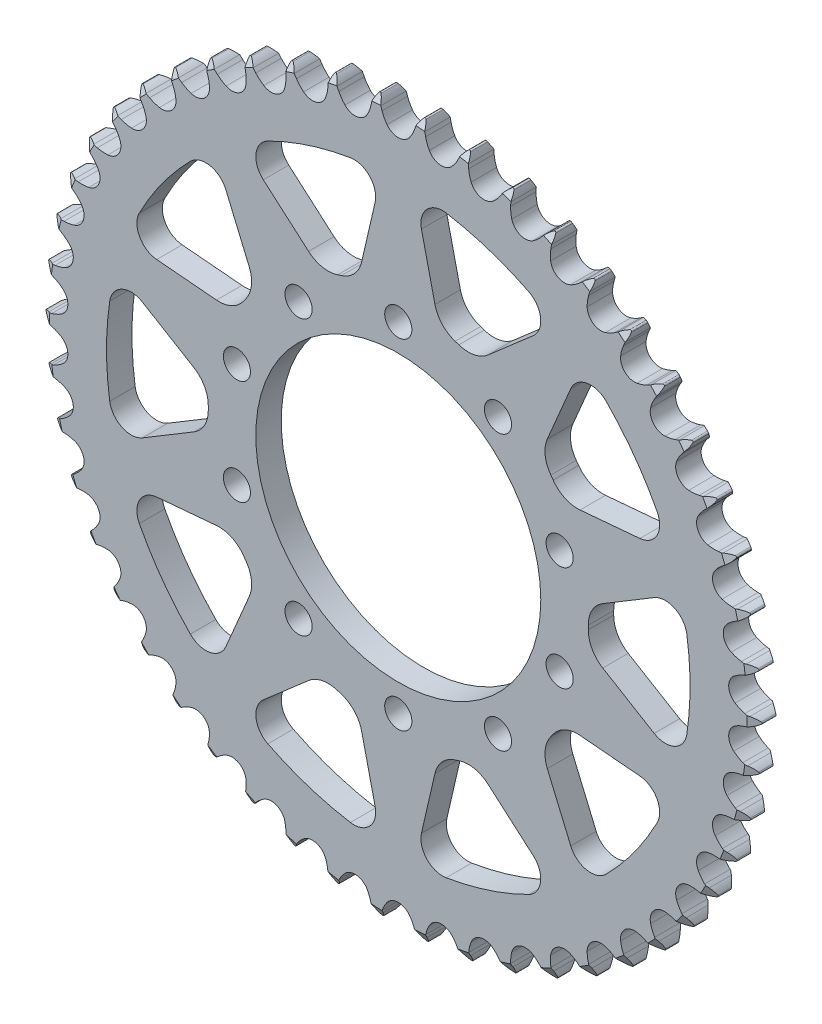
from build123d import *

# Parameters (mm, degrees)
BOSS_EXTRUDE1_DEPTH      = 4.6863
BOSS_EXTRUDE1_DEPTH_BACK = 4.6863
FILLET1_R                = 0.508
CUT_EXTRUDE1_DEPTH       = 187.877669954
CUT_EXTRUDE1_DEPTH_BACK  = 187.877669954
SKETCH2_R                = 5
SKETCH2_R_2              = 52.5
CUT_EXTRUDE2_DEPTH       = 187.877669954
CUT_EXTRUDE2_DEPTH_BACK  = 187.877669954


with BuildPart() as part:
    # Sketch1 → Boss-Extrude1 (new, two sides: drawn at the far end of the back side and taken through both)
    with BuildSketch(Plane.XY.offset(-BOSS_EXTRUDE1_DEPTH_BACK)):
        with BuildLine():
            Line((-5.965842416, 126.821796226), (-6.458669156, 128.227515271))
            ThreePointArc((-6.458669156, 128.227515271), (-7.217923563, 129.819672862), (-8.300150384, 131.21259))
            ThreePointArc((-8.300150384, 131.21259), (-9.199264715, 129.695017442), (-9.752981914, 128.02025468))
            Line((-9.752981914, 128.02025468), (-10.065739255, 126.563852581))
            ThreePointArc((-10.065739255, 126.563852581), (-10.615461473, 124.689641391), (-11.434310422, 122.916410301))
            ThreePointArc((-11.434310422, 122.916410301), (-15.288525396, 120.306617512), (-19.670682192, 121.875914574))
            ThreePointArc((-19.670682192, 121.875914574), (-20.904790136, 123.389796896), (-21.903339188, 125.068415939))
            Line((-21.903339188, 125.068415939), (-22.568463156, 126.4012829))
            ThreePointArc((-22.568463156, 126.4012829), (-23.521280874, 127.885726043), (-24.769552823, 129.132020627))
            ThreePointArc((-24.769552823, 129.132020627), (-25.471375093, 127.513725675), (-25.810822634, 125.78276975))
            Line((-25.810822634, 125.78276975), (-25.938578206, 124.298652928))
            ThreePointArc((-25.938578206, 124.298652928), (-26.249064751, 122.37032199), (-26.839212045, 120.50844437))
            ThreePointArc((-26.839212045, 120.50844437), (-30.335941613, 117.436169351), (-34.88022887, 118.443862156))
            ThreePointArc((-34.88022887, 118.443862156), (-36.29434527, 119.791132325), (-37.495407217, 121.331363574))
            Line((-37.495407217, 121.331363574), (-38.32233901, 122.570358343))
            ThreePointArc((-38.32233901, 122.570358343), (-39.453693535, 123.923676483), (-40.848324617, 125.003693702))
            ThreePointArc((-40.848324617, 125.003693702), (-41.341786669, 123.310197835), (-41.461611262, 121.550346956))
            Line((-41.461611262, 121.550346956), (-41.402350283, 120.06192082))
            ThreePointArc((-41.402350283, 120.06192082), (-41.468704597, 118.109881064), (-41.82084326, 116.188719837))
            ThreePointArc((-41.82084326, 116.188719837), (-44.904941909, 112.702414201), (-49.539693501, 113.132610831))
            ThreePointArc((-49.539693501, 113.132610831), (-51.111516898, 114.292021591), (-52.496150276, 115.669574678))
            Line((-52.496150276, 115.669574678), (-53.471848685, 116.795157568))
            ThreePointArc((-53.471848685, 116.795157568), (-54.76389788, 117.996008069), (-56.28289393, 118.892715407))
            ThreePointArc((-56.28289393, 118.892715407), (-56.560213574, 117.150726066), (-56.458525513, 115.389734134))
            Line((-56.458525513, 115.389734134), (-56.213182563, 113.920472052))
            ThreePointArc((-56.213182563, 113.920472052), (-56.034358199, 111.975508312), (-56.142934795, 110.025361338))
            ThreePointArc((-56.142934795, 110.025361338), (-58.765764446, 106.180006207), (-63.417887573, 106.025922204))
            ThreePointArc((-63.417887573, 106.025922204), (-65.122629372, 106.979188955), (-66.668997685, 108.172339046))
            Line((-66.668997685, 108.172339046), (-67.778075364, 109.166758942))
            ThreePointArc((-67.778075364, 109.166758942), (-69.210442842, 110.196203675), (-70.829848384, 110.89545952))
            ThreePointArc((-70.829848384, 110.89545952), (-70.886652123, 109.132448918), (-70.565055089, 107.398087827))
            Line((-70.565055089, 107.398087827), (-70.137499374, 105.971160941))
            ThreePointArc((-70.137499374, 105.971160941), (-69.716316499, 104.063946457), (-69.57961871, 102.115568717))
            ThreePointArc((-69.57961871, 102.115568717), (-71.699815773, 97.971807639), (-76.295943673, 97.235873))
            ThreePointArc((-76.295943673, 97.235873), (-78.106719078, 97.967962156), (-79.790435175, 98.957892561))
            Line((-79.790435175, 98.957892561), (-81.015401306, 99.805466868))
            ThreePointArc((-81.015401306, 99.805466868), (-82.565497775, 100.647270874), (-84.259773817, 101.138047545))
            ThreePointArc((-84.259773817, 101.138047545), (-84.095165822, 99.381819412), (-83.558731593, 97.701441072))
            Line((-83.558731593, 97.701441072), (-82.955705922, 96.33935287))
            ThreePointArc((-82.955705922, 96.33935287), (-82.298806842, 94.499965554), (-81.918990473, 92.584084131))
            ThreePointArc((-81.918990473, 92.584084131), (-83.503118174, 88.207266693), (-87.970767165, 86.901087547))
            ThreePointArc((-87.970767165, 86.901087547), (-89.859019166, 87.400453624), (-91.653529837, 88.17155255))
            Line((-91.653529837, 88.17155255), (-92.975065973, 88.858914514))
            ThreePointArc((-92.975065973, 88.858914514), (-94.618445487, 89.499802041), (-96.360872283, 89.774359697))
            ThreePointArc((-96.360872283, 89.774359697), (-95.97744852, 88.052610799), (-95.234636985, 86.45271578))
            Line((-95.234636985, 86.45271578), (-94.465651433, 85.176947209))
            ThreePointArc((-94.465651433, 85.176947209), (-93.583395837, 83.434395297), (-92.966450821, 81.581224785))
            ThreePointArc((-92.966450821, 81.581224785), (-93.989526519, 77.040376012), (-98.258239107, 75.184551584))
            ThreePointArc((-98.258239107, 75.184551584), (-100.194188843, 75.443319282), (-102.071193583, 75.983426037))
            Line((-102.071193583, 75.983426037), (-103.468458309, 76.499735549))
            ThreePointArc((-103.468458309, 76.499735549), (-105.17920379, 76.929599418), (-106.94230223, 76.98360812))
            ThreePointArc((-106.94230223, 76.98360812), (-106.346109521, 75.323491467), (-105.408635261, 73.82931107))
            Line((-105.408635261, 73.82931107), (-104.485817189, 72.659981761))
            ThreePointArc((-104.485817189, 72.659981761), (-103.392118777, 71.041746338), (-102.547774703, 69.280512343))
            ThreePointArc((-102.547774703, 69.280512343), (-102.993663884, 64.647244133), (-106.996119922, 62.271041884))
            ThreePointArc((-106.996119922, 62.271041884), (-108.949236308, 62.28513028), (-110.879133631, 62.585727059))
            Line((-110.879133631, 62.585727059), (-112.330091248, 62.92284161))
            ThreePointArc((-112.330091248, 62.92284161), (-114.081223219, 63.134902611), (-115.837188186, 62.96751061))
            ThreePointArc((-115.837188186, 62.96751061), (-115.037628847, 61.395207232), (-113.92027639, 60.030305575))
            Line((-113.92027639, 60.030305575), (-112.858179191, 58.985856549))
            ThreePointArc((-112.858179191, 58.985856549), (-111.570286239, 57.517458154), (-110.511858919, 55.875936388))
            ThreePointArc((-110.511858919, 55.875936388), (-110.373529644, 51.22331815), (-114.046608009, 48.364212207))
            ThreePointArc((-114.046608009, 48.364212207), (-115.986089234, 48.13339912), (-117.938443506, 48.189745332))
            Line((-117.938443506, 48.189745332), (-119.420211546, 48.342348424))
            ThreePointArc((-119.420211546, 48.342348424), (-121.184113609, 48.333262228), (-122.905252487, 47.947109396))
            ThreePointArc((-122.905252487, 47.947109396), (-121.914936046, 46.487415457), (-120.635326709, 45.273317853))
            Line((-120.635326709, 45.273317853), (-119.450700289, 44.370220696))
            ThreePointArc((-119.450700289, 44.370220696), (-117.988923639, 43.07481685), (-116.733105104, 41.578895091))
            ThreePointArc((-116.733105104, 41.578895091), (-116.012738908, 36.980301393), (-119.29851296, 33.683381566))
            ThreePointArc((-119.29851296, 33.683381566), (-121.193772245, 33.211307056), (-123.137793674, 33.022514087))
            Line((-123.137793674, 33.022514087), (-124.627003769, 32.988199078))
            ThreePointArc((-124.627003769, 32.988199078), (-126.375858136, 32.758108981), (-128.035027537, 32.159285177))
            ThreePointArc((-128.035027537, 32.159285177), (-126.869571875, 30.835220924), (-125.447885861, 29.791074418))
            Line((-125.447885861, 29.791074418), (-124.159412488, 29.043571511))
            ThreePointArc((-124.159412488, 29.043571511), (-122.54680523, 27.941591505), (-121.113400488, 26.614861335))
            ThreePointArc((-121.113400488, 26.614861335), (-119.822357977, 22.142814745), (-122.669009096, 18.46007543))
            ThreePointArc((-122.669009096, 18.46007543), (-124.490157071, 17.754184394), (-126.395187277, 17.323229622))
            Line((-126.395187277, 17.323229622), (-127.868353695, 17.10253768))
            ThreePointArc((-127.868353695, 17.10253768), (-129.574579886, 16.655072339), (-131.145613717, 15.853021374))
            ThreePointArc((-131.145613717, 15.853021374), (-129.823398767, 14.685468089), (-128.282056914, 13.827739496))
            Line((-128.282056914, 13.827739496), (-126.910056582, 13.247619407))
            ThreePointArc((-126.910056582, 13.247619407), (-125.172050497, 12.356442125), (-123.583665197, 11.219826869))
            ThreePointArc((-123.583665197, 11.219826869), (-121.742306882, 6.944854236), (-124.10494168, 2.93437443))
            ThreePointArc((-124.10494168, 2.93437443), (-125.823257753, 2.005799191), (-127.659253271, 1.33947903))
            Line((-127.659253271, 1.33947903), (-129.093143297, 0.9358906))
            ThreePointArc((-129.093143297, 0.9358906), (-130.729833108, 0.278106811), (-132.187955227, -0.714522492))
            ThreePointArc((-132.187955227, -0.714522492), (-130.729833108, -1.707151796), (-129.093143297, -2.364935585))
            Line((-129.093143297, -2.364935585), (-127.659253271, -2.768524015))
            ThreePointArc((-127.659253271, -2.768524015), (-125.823257753, -3.434844176), (-124.10494168, -4.363419415))
            ThreePointArc((-124.10494168, -4.363419415), (-121.742306882, -8.373899221), (-123.583665197, -12.648871854))
            ThreePointArc((-123.583665197, -12.648871854), (-125.172050497, -13.78548711), (-126.910056582, -14.676664392))
            Line((-126.910056582, -14.676664392), (-128.282056914, -15.256784481))
            ThreePointArc((-128.282056914, -15.256784481), (-129.823398767, -16.114513074), (-131.145613717, -17.282066359))
            ThreePointArc((-131.145613717, -17.282066359), (-129.574579886, -18.084117324), (-127.868353695, -18.531582665))
            Line((-127.868353695, -18.531582665), (-126.395187277, -18.752274607))
            ThreePointArc((-126.395187277, -18.752274607), (-124.490157071, -19.183229379), (-122.669009096, -19.889120415))
            ThreePointArc((-122.669009096, -19.889120415), (-119.822357977, -23.57185973), (-121.113400488, -28.04390632))
            ThreePointArc((-121.113400488, -28.04390632), (-122.54680523, -29.37063649), (-124.159412488, -30.472616496))
            Line((-124.159412488, -30.472616496), (-125.447885861, -31.220119403))
            ThreePointArc((-125.447885861, -31.220119403), (-126.869571875, -32.264265909), (-128.035027537, -33.588330162))
            ThreePointArc((-128.035027537, -33.588330162), (-126.375858136, -34.187153966), (-124.627003769, -34.417244063))
            Line((-124.627003769, -34.417244063), (-123.137793674, -34.451559072))
            ThreePointArc((-123.137793674, -34.451559072), (-121.193772245, -34.640352041), (-119.29851296, -35.112426551))
            ThreePointArc((-119.29851296, -35.112426551), (-116.012738908, -38.409346378), (-116.733105104, -43.007940076))
            ThreePointArc((-116.733105104, -43.007940076), (-117.988923639, -44.503861835), (-119.450700289, -45.799265681))
            Line((-119.450700289, -45.799265681), (-120.635326709, -46.702362838))
            ThreePointArc((-120.635326709, -46.702362838), (-121.914936046, -47.916460442), (-122.905252487, -49.376154381))
            ThreePointArc((-122.905252487, -49.376154381), (-121.184113609, -49.762307213), (-119.420211546, -49.771393409))
            Line((-119.420211546, -49.771393409), (-117.938443506, -49.618790317))
            ThreePointArc((-117.938443506, -49.618790317), (-115.986089234, -49.562444105), (-114.046608009, -49.793257192))
            ThreePointArc((-114.046608009, -49.793257192), (-110.373529644, -52.652363134), (-110.511858919, -57.304981373))
            ThreePointArc((-110.511858919, -57.304981373), (-111.570286239, -58.946503139), (-112.858179191, -60.414901534))
            Line((-112.858179191, -60.414901534), (-113.92027639, -61.45935056))
            ThreePointArc((-113.92027639, -61.45935056), (-115.037628847, -62.824252217), (-115.837188186, -64.396555595))
            ThreePointArc((-115.837188186, -64.396555595), (-114.081223219, -64.563947596), (-112.330091248, -64.351886595))
            Line((-112.330091248, -64.351886595), (-110.879133631, -64.014772044))
            ThreePointArc((-110.879133631, -64.014772044), (-108.949236308, -63.714175265), (-106.996119922, -63.700086869))
            ThreePointArc((-106.996119922, -63.700086869), (-102.993663884, -66.076289118), (-102.547774703, -70.709557328))
            ThreePointArc((-102.547774703, -70.709557328), (-103.392118777, -72.470791323), (-104.485817189, -74.089026746))
            Line((-104.485817189, -74.089026746), (-105.408635261, -75.258356055))
            ThreePointArc((-105.408635261, -75.258356055), (-106.346109521, -76.752536452), (-106.94230223, -78.412653105))
            ThreePointArc((-106.94230223, -78.412653105), (-105.17920379, -78.358644403), (-103.468458309, -77.928780534))
            Line((-103.468458309, -77.928780534), (-102.071193583, -77.412471022))
            ThreePointArc((-102.071193583, -77.412471022), (-100.194188843, -76.872364267), (-98.258239107, -76.613596569))
            ThreePointArc((-98.258239107, -76.613596569), (-93.989526519, -78.469420997), (-92.966450821, -83.01026977))
            ThreePointArc((-92.966450821, -83.01026977), (-93.583395837, -84.863440282), (-94.465651433, -86.605992194))
            Line((-94.465651433, -86.605992194), (-95.234636985, -87.881760765))
            ThreePointArc((-95.234636985, -87.881760765), (-95.97744852, -89.481655784), (-96.360872283, -91.203404682))
            ThreePointArc((-96.360872283, -91.203404682), (-94.618445487, -90.928847026), (-92.975065973, -90.287959498))
            Line((-92.975065973, -90.287959498), (-91.653529837, -89.600597535))
            ThreePointArc((-91.653529837, -89.600597535), (-89.859019166, -88.829498609), (-87.970767165, -88.330132532))
            ThreePointArc((-87.970767165, -88.330132532), (-83.503118174, -89.636311678), (-81.918990473, -94.013129116))
            ThreePointArc((-81.918990473, -94.013129116), (-82.298806842, -95.929010539), (-82.955705922, -97.768397855))
            Line((-82.955705922, -97.768397855), (-83.558731593, -99.130486057))
            ThreePointArc((-83.558731593, -99.130486057), (-84.095165822, -100.810864397), (-84.259773817, -102.56709253))
            ThreePointArc((-84.259773817, -102.56709253), (-82.565497775, -102.076315859), (-81.015401306, -101.234511853))
            Line((-81.015401306, -101.234511853), (-79.790435175, -100.386937546))
            ThreePointArc((-79.790435175, -100.386937546), (-78.106719078, -99.397007141), (-76.295943673, -98.664917985))
            ThreePointArc((-76.295943673, -98.664917985), (-71.699815773, -99.400852624), (-69.57961871, -103.544613702))
            ThreePointArc((-69.57961871, -103.544613702), (-69.716316499, -105.492991442), (-70.137499374, -107.400205925))
            Line((-70.137499374, -107.400205925), (-70.565055089, -108.827132812))
            ThreePointArc((-70.565055089, -108.827132812), (-70.886652123, -110.561493903), (-70.829848384, -112.324504505))
            ThreePointArc((-70.829848384, -112.324504505), (-69.210442842, -111.62524866), (-67.778075364, -110.595803927))
            Line((-67.778075364, -110.595803927), (-66.668997685, -109.601384031))
            ThreePointArc((-66.668997685, -109.601384031), (-65.122629372, -108.40823394), (-63.417887573, -107.454967189))
            ThreePointArc((-63.417887573, -107.454967189), (-58.765764446, -107.609051192), (-56.142934795, -111.454406323))
            ThreePointArc((-56.142934795, -111.454406323), (-56.034358199, -113.404553297), (-56.213182563, -115.349517037))
            Line((-56.213182563, -115.349517037), (-56.458525513, -116.818779119))
            ThreePointArc((-56.458525513, -116.818779119), (-56.560213574, -118.579771051), (-56.28289393, -120.321760392))
            ThreePointArc((-56.28289393, -120.321760392), (-54.76389788, -119.425053054), (-53.471848685, -118.224202553))
            Line((-53.471848685, -118.224202553), (-52.496150276, -117.098619663))
            ThreePointArc((-52.496150276, -117.098619663), (-51.111516898, -115.721066576), (-49.539693501, -114.561655816))
            ThreePointArc((-49.539693501, -114.561655816), (-44.904941909, -114.131459186), (-41.82084326, -117.617764822))
            ThreePointArc((-41.82084326, -117.617764822), (-41.468704597, -119.538926049), (-41.402350283, -121.490965805))
            Line((-41.402350283, -121.490965805), (-41.461611262, -122.979391941))
            ThreePointArc((-41.461611262, -122.979391941), (-41.341786669, -124.73924282), (-40.848324617, -126.432738687))
            ThreePointArc((-40.848324617, -126.432738687), (-39.453693535, -125.352721468), (-38.32233901, -123.999403328))
            Line((-38.32233901, -123.999403328), (-37.495407217, -122.760408559))
            ThreePointArc((-37.495407217, -122.760408559), (-36.29434527, -121.22017731), (-34.88022887, -119.872907141))
            ThreePointArc((-34.88022887, -119.872907141), (-30.335941613, -118.865214336), (-26.839212045, -121.937489355))
            ThreePointArc((-26.839212045, -121.937489355), (-26.249064751, -123.799366975), (-25.938578206, -125.727697913))
            Line((-25.938578206, -125.727697913), (-25.810822634, -127.211814735))
            ThreePointArc((-25.810822634, -127.211814735), (-25.471375093, -128.94277066), (-24.769552823, -130.561065612))
            ThreePointArc((-24.769552823, -130.561065612), (-23.521280874, -129.314771028), (-22.568463156, -127.830327885))
            Line((-22.568463156, -127.830327885), (-21.903339188, -126.497460924))
            ThreePointArc((-21.903339188, -126.497460924), (-20.904790136, -124.818841881), (-19.670682192, -123.304959559))
            ThreePointArc((-19.670682192, -123.304959559), (-15.288525396, -121.735662497), (-11.434310422, -124.345455286))
            ThreePointArc((-11.434310422, -124.345455286), (-10.615461473, -126.118686376), (-10.065739255, -127.992897566))
            Line((-10.065739255, -127.992897566), (-9.752981914, -129.449299665))
            ThreePointArc((-9.752981914, -129.449299665), (-9.199264715, -131.124062427), (-8.300150384, -132.641634985))
            ThreePointArc((-8.300150384, -132.641634985), (-7.217923563, -131.248717847), (-6.458669156, -129.656560256))
            Line((-6.458669156, -129.656560256), (-5.965842416, -128.250841211))
            ThreePointArc((-5.965842416, -128.250841211), (-5.185553973, -126.460307199), (-4.150917106, -124.803687552))
            ThreePointArc((-4.150917106, -124.803687552), (0, -122.697534985), (4.150917106, -124.803687552))
            ThreePointArc((4.150917106, -124.803687552), (5.185553973, -126.460307199), (5.965842416, -128.250841211))
            Line((5.965842416, -128.250841211), (6.458669156, -129.656560256))
            ThreePointArc((6.458669156, -129.656560256), (7.217923563, -131.248717847), (8.300150384, -132.641634985))
            ThreePointArc((8.300150384, -132.641634985), (9.199264715, -131.124062427), (9.752981914, -129.449299665))
            Line((9.752981914, -129.449299665), (10.065739255, -127.992897566))
            ThreePointArc((10.065739255, -127.992897566), (10.615461473, -126.118686376), (11.434310422, -124.345455286))
            ThreePointArc((11.434310422, -124.345455286), (15.288525396, -121.735662497), (19.670682192, -123.304959559))
            ThreePointArc((19.670682192, -123.304959559), (20.904790136, -124.818841881), (21.903339188, -126.497460924))
            Line((21.903339188, -126.497460924), (22.568463156, -127.830327885))
            ThreePointArc((22.568463156, -127.830327885), (23.521280874, -129.314771028), (24.769552823, -130.561065612))
            ThreePointArc((24.769552823, -130.561065612), (25.471375093, -128.94277066), (25.810822634, -127.211814735))
            Line((25.810822634, -127.211814735), (25.938578206, -125.727697913))
            ThreePointArc((25.938578206, -125.727697913), (26.249064751, -123.799366975), (26.839212045, -121.937489355))
            ThreePointArc((26.839212045, -121.937489355), (30.335941613, -118.865214336), (34.88022887, -119.872907141))
            ThreePointArc((34.88022887, -119.872907141), (36.29434527, -121.22017731), (37.495407217, -122.760408559))
            Line((37.495407217, -122.760408559), (38.32233901, -123.999403328))
            ThreePointArc((38.32233901, -123.999403328), (39.453693535, -125.352721468), (40.848324617, -126.432738687))
            ThreePointArc((40.848324617, -126.432738687), (41.341786669, -124.73924282), (41.461611262, -122.979391941))
            Line((41.461611262, -122.979391941), (41.402350283, -121.490965805))
            ThreePointArc((41.402350283, -121.490965805), (41.468704597, -119.538926049), (41.82084326, -117.617764822))
            ThreePointArc((41.82084326, -117.617764822), (44.904941909, -114.131459186), (49.539693501, -114.561655816))
            ThreePointArc((49.539693501, -114.561655816), (51.111516898, -115.721066576), (52.496150276, -117.098619663))
            Line((52.496150276, -117.098619663), (53.471848685, -118.224202553))
            ThreePointArc((53.471848685, -118.224202553), (54.76389788, -119.425053054), (56.28289393, -120.321760392))
            ThreePointArc((56.28289393, -120.321760392), (56.560213574, -118.579771051), (56.458525513, -116.818779119))
            Line((56.458525513, -116.818779119), (56.213182563, -115.349517037))
            ThreePointArc((56.213182563, -115.349517037), (56.034358199, -113.404553297), (56.142934795, -111.454406323))
            ThreePointArc((56.142934795, -111.454406323), (58.765764446, -107.609051192), (63.417887573, -107.454967189))
            ThreePointArc((63.417887573, -107.454967189), (65.122629372, -108.40823394), (66.668997685, -109.601384031))
            Line((66.668997685, -109.601384031), (67.778075364, -110.595803927))
            ThreePointArc((67.778075364, -110.595803927), (69.210442842, -111.62524866), (70.829848384, -112.324504505))
            ThreePointArc((70.829848384, -112.324504505), (70.886652123, -110.561493903), (70.565055089, -108.827132812))
            Line((70.565055089, -108.827132812), (70.137499374, -107.400205925))
            ThreePointArc((70.137499374, -107.400205925), (69.716316499, -105.492991442), (69.57961871, -103.544613702))
            ThreePointArc((69.57961871, -103.544613702), (71.699815773, -99.400852624), (76.295943673, -98.664917985))
            ThreePointArc((76.295943673, -98.664917985), (78.106719078, -99.397007141), (79.790435175, -100.386937546))
            Line((79.790435175, -100.386937546), (81.015401306, -101.234511853))
            ThreePointArc((81.015401306, -101.234511853), (82.565497775, -102.076315859), (84.259773817, -102.56709253))
            ThreePointArc((84.259773817, -102.56709253), (84.095165822, -100.810864397), (83.558731593, -99.130486057))
            Line((83.558731593, -99.130486057), (82.955705922, -97.768397855))
            ThreePointArc((82.955705922, -97.768397855), (82.298806842, -95.929010539), (81.918990473, -94.013129116))
            ThreePointArc((81.918990473, -94.013129116), (83.503118174, -89.636311678), (87.970767165, -88.330132532))
            ThreePointArc((87.970767165, -88.330132532), (89.859019166, -88.829498609), (91.653529837, -89.600597535))
            Line((91.653529837, -89.600597535), (92.975065973, -90.287959498))
            ThreePointArc((92.975065973, -90.287959498), (94.618445487, -90.928847026), (96.360872283, -91.203404682))
            ThreePointArc((96.360872283, -91.203404682), (95.97744852, -89.481655784), (95.234636985, -87.881760765))
            Line((95.234636985, -87.881760765), (94.465651433, -86.605992194))
            ThreePointArc((94.465651433, -86.605992194), (93.583395837, -84.863440282), (92.966450821, -83.01026977))
            ThreePointArc((92.966450821, -83.01026977), (93.989526519, -78.469420997), (98.258239107, -76.613596569))
            ThreePointArc((98.258239107, -76.613596569), (100.194188843, -76.872364267), (102.071193583, -77.412471022))
            Line((102.071193583, -77.412471022), (103.468458309, -77.928780534))
            ThreePointArc((103.468458309, -77.928780534), (105.17920379, -78.358644403), (106.94230223, -78.412653105))
            ThreePointArc((106.94230223, -78.412653105), (106.346109521, -76.752536452), (105.408635261, -75.258356055))
            Line((105.408635261, -75.258356055), (104.485817189, -74.089026746))
            ThreePointArc((104.485817189, -74.089026746), (103.392118777, -72.470791323), (102.547774703, -70.709557328))
            ThreePointArc((102.547774703, -70.709557328), (102.993663884, -66.076289118), (106.996119922, -63.700086869))
            ThreePointArc((106.996119922, -63.700086869), (108.949236308, -63.714175265), (110.879133631, -64.014772044))
            Line((110.879133631, -64.014772044), (112.330091248, -64.351886595))
            ThreePointArc((112.330091248, -64.351886595), (114.081223219, -64.563947596), (115.837188186, -64.396555595))
            ThreePointArc((115.837188186, -64.396555595), (115.037628847, -62.824252217), (113.92027639, -61.45935056))
            Line((113.92027639, -61.45935056), (112.858179191, -60.414901534))
            ThreePointArc((112.858179191, -60.414901534), (111.570286239, -58.946503139), (110.511858919, -57.304981373))
            ThreePointArc((110.511858919, -57.304981373), (110.373529644, -52.652363134), (114.046608009, -49.793257192))
            ThreePointArc((114.046608009, -49.793257192), (115.986089234, -49.562444105), (117.938443506, -49.618790317))
            Line((117.938443506, -49.618790317), (119.420211546, -49.771393409))
            ThreePointArc((119.420211546, -49.771393409), (121.184113609, -49.762307213), (122.905252487, -49.376154381))
            ThreePointArc((122.905252487, -49.376154381), (121.914936046, -47.916460442), (120.635326709, -46.702362838))
            Line((120.635326709, -46.702362838), (119.450700289, -45.799265681))
            ThreePointArc((119.450700289, -45.799265681), (117.988923639, -44.503861835), (116.733105104, -43.007940076))
            ThreePointArc((116.733105104, -43.007940076), (116.012738908, -38.409346378), (119.29851296, -35.112426551))
            ThreePointArc((119.29851296, -35.112426551), (121.193772245, -34.640352041), (123.137793674, -34.451559072))
            Line((123.137793674, -34.451559072), (124.627003769, -34.417244063))
            ThreePointArc((124.627003769, -34.417244063), (126.375858136, -34.187153966), (128.035027537, -33.588330162))
            ThreePointArc((128.035027537, -33.588330162), (126.869571875, -32.264265909), (125.447885861, -31.220119403))
            Line((125.447885861, -31.220119403), (124.159412488, -30.472616496))
            ThreePointArc((124.159412488, -30.472616496), (122.54680523, -29.37063649), (121.113400488, -28.04390632))
            ThreePointArc((121.113400488, -28.04390632), (119.822357977, -23.57185973), (122.669009096, -19.889120415))
            ThreePointArc((122.669009096, -19.889120415), (124.490157071, -19.183229379), (126.395187277, -18.752274607))
            Line((126.395187277, -18.752274607), (127.868353695, -18.531582665))
            ThreePointArc((127.868353695, -18.531582665), (129.574579886, -18.084117324), (131.145613717, -17.282066359))
            ThreePointArc((131.145613717, -17.282066359), (129.823398767, -16.114513074), (128.282056914, -15.256784481))
            Line((128.282056914, -15.256784481), (126.910056582, -14.676664392))
            ThreePointArc((126.910056582, -14.676664392), (125.172050497, -13.78548711), (123.583665197, -12.648871854))
            ThreePointArc((123.583665197, -12.648871854), (121.742306882, -8.373899221), (124.10494168, -4.363419415))
            ThreePointArc((124.10494168, -4.363419415), (125.823257753, -3.434844176), (127.659253271, -2.768524015))
            Line((127.659253271, -2.768524015), (129.093143297, -2.364935585))
            ThreePointArc((129.093143297, -2.364935585), (130.729833108, -1.707151796), (132.187955227, -0.714522492))
            ThreePointArc((132.187955227, -0.714522492), (130.729833108, 0.278106811), (129.093143297, 0.9358906))
            Line((129.093143297, 0.9358906), (127.659253271, 1.33947903))
            ThreePointArc((127.659253271, 1.33947903), (125.823257753, 2.005799191), (124.10494168, 2.93437443))
            ThreePointArc((124.10494168, 2.93437443), (121.742306882, 6.944854236), (123.583665197, 11.219826869))
            ThreePointArc((123.583665197, 11.219826869), (125.172050497, 12.356442125), (126.910056582, 13.247619407))
            Line((126.910056582, 13.247619407), (128.282056914, 13.827739496))
            ThreePointArc((128.282056914, 13.827739496), (129.823398767, 14.685468089), (131.145613717, 15.853021374))
            ThreePointArc((131.145613717, 15.853021374), (129.574579886, 16.655072339), (127.868353695, 17.10253768))
            Line((127.868353695, 17.10253768), (126.395187277, 17.323229622))
            ThreePointArc((126.395187277, 17.323229622), (124.490157071, 17.754184394), (122.669009096, 18.46007543))
            ThreePointArc((122.669009096, 18.46007543), (119.822357977, 22.142814745), (121.113400488, 26.614861335))
            ThreePointArc((121.113400488, 26.614861335), (122.54680523, 27.941591505), (124.159412488, 29.043571511))
            Line((124.159412488, 29.043571511), (125.447885861, 29.791074418))
            ThreePointArc((125.447885861, 29.791074418), (126.869571875, 30.835220924), (128.035027537, 32.159285177))
            ThreePointArc((128.035027537, 32.159285177), (126.375858136, 32.758108981), (124.627003769, 32.988199078))
            Line((124.627003769, 32.988199078), (123.137793674, 33.022514087))
            ThreePointArc((123.137793674, 33.022514087), (121.193772245, 33.211307056), (119.29851296, 33.683381566))
            ThreePointArc((119.29851296, 33.683381566), (116.012738908, 36.980301393), (116.733105104, 41.578895091))
            ThreePointArc((116.733105104, 41.578895091), (117.988923639, 43.07481685), (119.450700289, 44.370220696))
            Line((119.450700289, 44.370220696), (120.635326709, 45.273317853))
            ThreePointArc((120.635326709, 45.273317853), (121.914936046, 46.487415457), (122.905252487, 47.947109396))
            ThreePointArc((122.905252487, 47.947109396), (121.184113609, 48.333262228), (119.420211546, 48.342348424))
            Line((119.420211546, 48.342348424), (117.938443506, 48.189745332))
            ThreePointArc((117.938443506, 48.189745332), (115.986089234, 48.13339912), (114.046608009, 48.364212207))
            ThreePointArc((114.046608009, 48.364212207), (110.373529644, 51.22331815), (110.511858919, 55.875936388))
            ThreePointArc((110.511858919, 55.875936388), (111.570286239, 57.517458154), (112.858179191, 58.985856549))
            Line((112.858179191, 58.985856549), (113.92027639, 60.030305575))
            ThreePointArc((113.92027639, 60.030305575), (115.037628847, 61.395207232), (115.837188186, 62.96751061))
            ThreePointArc((115.837188186, 62.96751061), (114.081223219, 63.134902611), (112.330091248, 62.92284161))
            Line((112.330091248, 62.92284161), (110.879133631, 62.585727059))
            ThreePointArc((110.879133631, 62.585727059), (108.949236308, 62.28513028), (106.996119922, 62.271041884))
            ThreePointArc((106.996119922, 62.271041884), (102.993663884, 64.647244133), (102.547774703, 69.280512343))
            ThreePointArc((102.547774703, 69.280512343), (103.392118777, 71.041746338), (104.485817189, 72.659981761))
            Line((104.485817189, 72.659981761), (105.408635261, 73.82931107))
            ThreePointArc((105.408635261, 73.82931107), (106.346109521, 75.323491467), (106.94230223, 76.98360812))
            ThreePointArc((106.94230223, 76.98360812), (105.17920379, 76.929599418), (103.468458309, 76.499735549))
            Line((103.468458309, 76.499735549), (102.071193583, 75.983426037))
            ThreePointArc((102.071193583, 75.983426037), (100.194188843, 75.443319282), (98.258239107, 75.184551584))
            ThreePointArc((98.258239107, 75.184551584), (93.989526519, 77.040376012), (92.966450821, 81.581224785))
            ThreePointArc((92.966450821, 81.581224785), (93.583395837, 83.434395297), (94.465651433, 85.176947209))
            Line((94.465651433, 85.176947209), (95.234636985, 86.45271578))
            ThreePointArc((95.234636985, 86.45271578), (95.97744852, 88.052610799), (96.360872283, 89.774359697))
            ThreePointArc((96.360872283, 89.774359697), (94.618445487, 89.499802041), (92.975065973, 88.858914514))
            Line((92.975065973, 88.858914514), (91.653529837, 88.17155255))
            ThreePointArc((91.653529837, 88.17155255), (89.859019166, 87.400453624), (87.970767165, 86.901087547))
            ThreePointArc((87.970767165, 86.901087547), (83.503118174, 88.207266693), (81.918990473, 92.584084131))
            ThreePointArc((81.918990473, 92.584084131), (82.298806842, 94.499965554), (82.955705922, 96.33935287))
            Line((82.955705922, 96.33935287), (83.558731593, 97.701441072))
            ThreePointArc((83.558731593, 97.701441072), (84.095165822, 99.381819412), (84.259773817, 101.138047545))
            ThreePointArc((84.259773817, 101.138047545), (82.565497775, 100.647270874), (81.015401306, 99.805466868))
            Line((81.015401306, 99.805466868), (79.790435175, 98.957892561))
            ThreePointArc((79.790435175, 98.957892561), (78.106719078, 97.967962156), (76.295943673, 97.235873))
            ThreePointArc((76.295943673, 97.235873), (71.699815773, 97.971807639), (69.57961871, 102.115568717))
            ThreePointArc((69.57961871, 102.115568717), (69.716316499, 104.063946457), (70.137499374, 105.971160941))
            Line((70.137499374, 105.971160941), (70.565055089, 107.398087827))
            ThreePointArc((70.565055089, 107.398087827), (70.886652123, 109.132448918), (70.829848384, 110.89545952))
            ThreePointArc((70.829848384, 110.89545952), (69.210442842, 110.196203675), (67.778075364, 109.166758942))
            Line((67.778075364, 109.166758942), (66.668997685, 108.172339046))
            ThreePointArc((66.668997685, 108.172339046), (65.122629372, 106.979188955), (63.417887573, 106.025922204))
            ThreePointArc((63.417887573, 106.025922204), (58.765764446, 106.180006207), (56.142934795, 110.025361338))
            ThreePointArc((56.142934795, 110.025361338), (56.034358199, 111.975508312), (56.213182563, 113.920472052))
            Line((56.213182563, 113.920472052), (56.458525513, 115.389734134))
            ThreePointArc((56.458525513, 115.389734134), (56.560213574, 117.150726066), (56.28289393, 118.892715407))
            ThreePointArc((56.28289393, 118.892715407), (54.76389788, 117.996008069), (53.471848685, 116.795157568))
            Line((53.471848685, 116.795157568), (52.496150276, 115.669574678))
            ThreePointArc((52.496150276, 115.669574678), (51.111516898, 114.292021591), (49.539693501, 113.132610831))
            ThreePointArc((49.539693501, 113.132610831), (44.904941909, 112.702414201), (41.82084326, 116.188719837))
            ThreePointArc((41.82084326, 116.188719837), (41.468704597, 118.109881064), (41.402350283, 120.06192082))
            Line((41.402350283, 120.06192082), (41.461611262, 121.550346956))
            ThreePointArc((41.461611262, 121.550346956), (41.341786669, 123.310197835), (40.848324617, 125.003693702))
            ThreePointArc((40.848324617, 125.003693702), (39.453693535, 123.923676483), (38.32233901, 122.570358343))
            Line((38.32233901, 122.570358343), (37.495407217, 121.331363574))
            ThreePointArc((37.495407217, 121.331363574), (36.29434527, 119.791132325), (34.88022887, 118.443862156))
            ThreePointArc((34.88022887, 118.443862156), (30.335941613, 117.436169351), (26.839212045, 120.50844437))
            ThreePointArc((26.839212045, 120.50844437), (26.249064751, 122.37032199), (25.938578206, 124.298652928))
            Line((25.938578206, 124.298652928), (25.810822634, 125.78276975))
            ThreePointArc((25.810822634, 125.78276975), (25.471375093, 127.513725675), (24.769552823, 129.132020627))
            ThreePointArc((24.769552823, 129.132020627), (23.521280874, 127.885726043), (22.568463156, 126.4012829))
            Line((22.568463156, 126.4012829), (21.903339188, 125.068415939))
            ThreePointArc((21.903339188, 125.068415939), (20.904790136, 123.389796896), (19.670682192, 121.875914574))
            ThreePointArc((19.670682192, 121.875914574), (15.288525396, 120.306617512), (11.434310422, 122.916410301))
            ThreePointArc((11.434310422, 122.916410301), (10.615461473, 124.689641391), (10.065739255, 126.563852581))
            Line((10.065739255, 126.563852581), (9.752981914, 128.02025468))
            ThreePointArc((9.752981914, 128.02025468), (9.199264715, 129.695017442), (8.300150384, 131.21259))
            ThreePointArc((8.300150384, 131.21259), (7.217923563, 129.819672862), (6.458669156, 128.227515271))
            Line((6.458669156, 128.227515271), (5.965842416, 126.821796226))
            ThreePointArc((5.965842416, 126.821796226), (5.185553973, 125.031262214), (4.150917106, 123.374642567))
            ThreePointArc((4.150917106, 123.374642567), (0, 121.26849), (-4.150917106, 123.374642567))
            ThreePointArc((-4.150917106, 123.374642567), (-5.185553973, 125.031262214), (-5.965842416, 126.821796226))
        make_face()
    extrude(amount=BOSS_EXTRUDE1_DEPTH + BOSS_EXTRUDE1_DEPTH_BACK)

    # Fillet1
    fillet1_edges = [part.edges().sort_by_distance(p)[0] for p in [
        (-56.28289393, 118.892715407, 0),
        (-70.829848384, 110.89545952, 0),
        (-84.259773817, 101.138047545, 0),
        (-96.360872283, 89.774359697, 0),
        (-106.94230223, 76.98360812, 0),
        (-115.837188186, 62.96751061, 0),
        (-122.905252487, 47.947109396, 0),
        (-128.035027537, 32.159285177, 0),
        (-131.145613717, 15.853021374, 0),
        (-132.187955227, -0.714522492, 0),
        (-131.145613717, -17.282066359, 0),
        (-128.035027537, -33.588330162, 0),
        (-122.905252487, -49.376154381, 0),
        (-115.837188186, -64.396555595, 0),
        (-106.94230223, -78.412653105, 0),
        (-96.360872283, -91.203404682, 0),
        (-84.259773817, -102.56709253, 0),
        (-70.829848384, -112.324504505, 0),
        (-56.28289393, -120.321760392, 0),
        (-40.848324617, -126.432738687, 0),
        (-24.769552823, -130.561065612, 0),
        (-8.300150384, -132.641634985, 0),
        (8.300150384, -132.641634985, 0),
        (24.769552823, -130.561065612, 0),
        (40.848324617, -126.432738687, 0),
        (56.28289393, -120.321760392, 0),
        (70.829848384, -112.324504505, 0),
        (84.259773817, -102.56709253, 0),
        (96.360872283, -91.203404682, 0),
        (106.94230223, -78.412653105, 0),
        (115.837188186, -64.396555595, 0),
        (122.905252487, -49.376154381, 0),
        (128.035027537, -33.588330162, 0),
        (131.145613717, -17.282066359, 0),
        (132.187955227, -0.714522492, 0),
        (131.145613717, 15.853021374, 0),
        (128.035027537, 32.159285177, 0),
        (122.905252487, 47.947109396, 0),
        (115.837188186, 62.96751061, 0),
        (106.94230223, 76.98360812, 0),
        (96.360872283, 89.774359697, 0),
        (-40.848324617, 125.003693702, 0),
        (-24.769552823, 129.132020627, 0),
        (-8.300150384, 131.21259, 0),
        (84.259773817, 101.138047545, 0),
        (70.829848384, 110.89545952, 0),
        (56.28289393, 118.892715407, 0),
        (40.848324617, 125.003693702, 0),
        (24.769552823, 129.132020627, 0),
        (8.300150384, 131.21259, 0),
    ]]
    fillet(fillet1_edges, radius=FILLET1_R)

    # Sketch2 → Cut-Extrude1 (cut, two sides: drawn at the far end of the back side and taken through both)
    with BuildSketch(Plane.XY.offset(-CUT_EXTRUDE1_DEPTH_BACK)):
        with Locations((0, 62.5)):
            Circle(SKETCH2_R)
        with Locations((36.736578268, 50.563562148)):
            Circle(SKETCH2_R)
        with Locations((59.441032268, 19.313562148)):
            Circle(SKETCH2_R)
        with Locations((59.441032268, -19.313562148)):
            Circle(SKETCH2_R)
        with Locations((36.736578268, -50.563562148)):
            Circle(SKETCH2_R)
        with Locations((0, -62.5)):
            Circle(SKETCH2_R)
        with Locations((-36.736578268, -50.563562148)):
            Circle(SKETCH2_R)
        with Locations((-59.441032268, -19.313562148)):
            Circle(SKETCH2_R)
        with Locations((-59.441032268, 19.313562148)):
            Circle(SKETCH2_R)
        with Locations((-36.736578268, 50.563562148)):
            Circle(SKETCH2_R)
        Circle(SKETCH2_R_2)
    extrude(amount=CUT_EXTRUDE1_DEPTH + CUT_EXTRUDE1_DEPTH_BACK, mode=Mode.SUBTRACT)

    # Sketch3 → Cut-Extrude2 (cut, two sides: drawn at the far end of the back side and taken through both)
    with BuildSketch(Plane.XY.offset(-CUT_EXTRUDE2_DEPTH_BACK)):
        with BuildLine():
            Line((8.53646074, 96.350292361), (13.510002491, 74.816307265))
            ThreePointArc((13.510002491, 74.816307265), (16.156889401, 69.817802093), (20.937649661, 66.795320395))
            ThreePointArc((20.937649661, 66.795320395), (21.631914332, 66.573720659), (22.323834325, 66.344905012))
            ThreePointArc((22.323834325, 66.344905012), (27.968112844, 65.979960807), (33.04759113, 68.467924757))
            Line((33.04759113, 68.467924757), (49.728945438, 82.965546979))
            ThreePointArc((49.728945438, 82.965546979), (52.4177185, 90.00919298), (48.057518394, 96.159892501))
            ThreePointArc((48.057518394, 96.159892501), (40.7519201, 99.476283647), (33.219326895, 102.238575502))
            ThreePointArc((33.219326895, 102.238575502), (25.50283341, 104.431104026), (17.644326349, 106.042103656))
            ThreePointArc((17.644326349, 106.042103656), (10.501507357, 103.629100048), (8.53646074, 96.350292361))
        make_face()
        with BuildLine():
            Line((66.980499274, 35.966828008), (88.997486935, 37.890596713))
            ThreePointArc((88.997486935, 37.890596713), (95.312901277, 42.008604878), (95.400715762, 49.547486637))
            ThreePointArc((95.400715762, 49.547486637), (91.439688394, 56.524626371), (86.969326895, 63.186914621))
            ThreePointArc((86.969326895, 63.186914621), (82.01528846, 69.496348528), (76.604544521, 75.418789162))
            ThreePointArc((76.604544521, 75.418789162), (69.407554635, 77.6650719), (63.539422715, 72.931418203))
            Line((63.539422715, 72.931418203), (54.90574365, 52.586683811))
            ThreePointArc((54.90574365, 52.586683811), (54.109072519, 46.98700709), (56.200218648, 41.731707656))
            ThreePointArc((56.200218648, 41.731707656), (56.631637509, 41.144351168), (57.056918079, 40.552535054))
            ThreePointArc((57.056918079, 40.552535054), (61.408726501, 36.939665317), (66.980499274, 35.966828008))
        make_face()
        with BuildLine():
            Line((75.32913328, -10.272374572), (94.272013336, -21.657273643))
            ThreePointArc((94.272013336, -21.657273643), (101.801795333, -22.037842467), (106.304082261, -15.990375065))
            ThreePointArc((106.304082261, -15.990375065), (107.200603643, -8.017516978), (107.5, 0))
            ThreePointArc((107.5, 0), (107.200690916, 8.016349987), (106.304430379, 15.988060599))
            ThreePointArc((106.304430379, 15.988060599), (101.802275119, 22.035626024), (94.272484837, 21.655221139))
            Line((94.272484837, 21.655221139), (75.329356913, 10.270734497))
            ThreePointArc((75.329356913, 10.270734497), (71.393429035, 6.208772408), (69.996214287, 0.728001001))
            ThreePointArc((69.996214287, 0.728001001), (69.999999996, -0.000762023), (69.996198421, -0.729524965))
            ThreePointArc((69.996198421, -0.729524965), (71.39329384, -6.210326791), (75.32913328, -10.272374572))
        make_face()
        with BuildLine():
            Line((54.904598715, -52.587879211), (63.53783483, -72.932801572))
            ThreePointArc((63.53783483, -72.932801572), (69.405863687, -77.666583029), (76.602902478, -75.420456986))
            ThreePointArc((76.602902478, -75.420456986), (82.014531915, -69.497241346), (86.969326895, -63.186914621))
            ThreePointArc((86.969326895, -63.186914621), (91.439073059, -56.525621784), (95.399636987, -49.549563698))
            ThreePointArc((95.399636987, -49.549563698), (95.311986639, -42.01068003), (88.996661956, -37.892534366))
            Line((88.996661956, -37.892534366), (66.979716185, -35.968286305))
            ThreePointArc((66.979716185, -35.968286305), (61.407922232, -36.941002305), (57.056035152, -40.553777293))
            ThreePointArc((57.056035152, -40.553777293), (56.630741697, -41.145584148), (56.199310048, -41.732931243))
            ThreePointArc((56.199310048, -41.732931243), (54.108049501, -46.988185147), (54.904598715, -52.587879211))
        make_face()
        with BuildLine():
            Line((13.50837358, -74.816601388), (8.534362991, -96.350478195))
            ThreePointArc((8.534362991, -96.350478195), (10.499251132, -103.629328664), (17.642017586, -106.042487784))
            ThreePointArc((17.642017586, -106.042487784), (25.501696567, -104.431381645), (33.219326895, -102.238575502))
            ThreePointArc((33.219326895, -102.238575502), (40.750837194, -99.476727268), (48.05542478, -96.160938791))
            ThreePointArc((48.05542478, -96.160938791), (52.415758799, -90.010334202), (49.727139093, -82.966629663))
            Line((49.727139093, -82.966629663), (33.046100432, -68.468644256))
            ThreePointArc((33.046100432, -68.468644256), (27.966676316, -65.980569716), (22.322389853, -66.345391033))
            ThreePointArc((22.322389853, -66.345391033), (21.630464878, -66.574191615), (20.936195382, -66.795776236))
            ThreePointArc((20.936195382, -66.795776236), (16.155369318, -69.818153845), (13.50837358, -74.816601388))
        make_face()
        with BuildLine():
            Line((-33.04759113, -68.467924757), (-49.728945438, -82.965546979))
            ThreePointArc((-49.728945438, -82.965546979), (-52.4177185, -90.00919298), (-48.057518394, -96.159892501))
            ThreePointArc((-48.057518394, -96.159892501), (-40.7519201, -99.476283647), (-33.219326895, -102.238575502))
            ThreePointArc((-33.219326895, -102.238575502), (-25.50283341, -104.431104026), (-17.644326349, -106.042103656))
            ThreePointArc((-17.644326349, -106.042103656), (-10.501507357, -103.629100048), (-8.53646074, -96.350292361))
            Line((-8.53646074, -96.350292361), (-13.510002491, -74.816307265))
            ThreePointArc((-13.510002491, -74.816307265), (-16.156889401, -69.817802093), (-20.937649661, -66.795320395))
            ThreePointArc((-20.937649661, -66.795320395), (-21.631914332, -66.573720659), (-22.323834325, -66.344905012))
            ThreePointArc((-22.323834325, -66.344905012), (-27.968112844, -65.979960807), (-33.04759113, -68.467924757))
        make_face()
        with BuildLine():
            Line((-66.980499274, -35.966828008), (-88.997486935, -37.890596713))
            ThreePointArc((-88.997486935, -37.890596713), (-95.312901277, -42.008604878), (-95.400715762, -49.547486637))
            ThreePointArc((-95.400715762, -49.547486637), (-91.439688394, -56.524626371), (-86.969326895, -63.186914621))
            ThreePointArc((-86.969326895, -63.186914621), (-82.01528846, -69.496348528), (-76.604544521, -75.418789162))
            ThreePointArc((-76.604544521, -75.418789162), (-69.407554635, -77.6650719), (-63.539422715, -72.931418203))
            Line((-63.539422715, -72.931418203), (-54.90574365, -52.586683811))
            ThreePointArc((-54.90574365, -52.586683811), (-54.109072519, -46.98700709), (-56.200218648, -41.731707656))
            ThreePointArc((-56.200218648, -41.731707656), (-56.631637509, -41.144351168), (-57.056918079, -40.552535054))
            ThreePointArc((-57.056918079, -40.552535054), (-61.408726501, -36.939665317), (-66.980499274, -35.966828008))
        make_face()
        with BuildLine():
            Line((-75.32913328, 10.272374572), (-94.272013336, 21.657273643))
            ThreePointArc((-94.272013336, 21.657273643), (-101.801795333, 22.037842467), (-106.304082261, 15.990375065))
            ThreePointArc((-106.304082261, 15.990375065), (-107.200603643, 8.017516978), (-107.5, 0))
            ThreePointArc((-107.5, 0), (-107.200690916, -8.016349987), (-106.304430379, -15.988060599))
            ThreePointArc((-106.304430379, -15.988060599), (-101.802275119, -22.035626024), (-94.272484837, -21.655221139))
            Line((-94.272484837, -21.655221139), (-75.329356913, -10.270734497))
            ThreePointArc((-75.329356913, -10.270734497), (-71.393429035, -6.208772408), (-69.996214287, -0.728001001))
            ThreePointArc((-69.996214287, -0.728001001), (-69.999999996, 0.000762023), (-69.996198421, 0.729524965))
            ThreePointArc((-69.996198421, 0.729524965), (-71.39329384, 6.210326791), (-75.32913328, 10.272374572))
        make_face()
        with BuildLine():
            Line((-54.904598715, 52.587879211), (-63.53783483, 72.932801572))
            ThreePointArc((-63.53783483, 72.932801572), (-69.405863687, 77.666583029), (-76.602902478, 75.420456986))
            ThreePointArc((-76.602902478, 75.420456986), (-82.014531915, 69.497241346), (-86.969326895, 63.186914621))
            ThreePointArc((-86.969326895, 63.186914621), (-91.439073059, 56.525621784), (-95.399636987, 49.549563698))
            ThreePointArc((-95.399636987, 49.549563698), (-95.311986639, 42.01068003), (-88.996661956, 37.892534366))
            Line((-88.996661956, 37.892534366), (-66.979716185, 35.968286305))
            ThreePointArc((-66.979716185, 35.968286305), (-61.407922232, 36.941002305), (-57.056035152, 40.553777293))
            ThreePointArc((-57.056035152, 40.553777293), (-56.630741697, 41.145584148), (-56.199310048, 41.732931243))
            ThreePointArc((-56.199310048, 41.732931243), (-54.108049501, 46.988185147), (-54.904598715, 52.587879211))
        make_face()
        with BuildLine():
            Line((-13.50837358, 74.816601388), (-8.534362991, 96.350478195))
            ThreePointArc((-8.534362991, 96.350478195), (-10.499251132, 103.629328664), (-17.642017586, 106.042487784))
            ThreePointArc((-17.642017586, 106.042487784), (-25.501696567, 104.431381645), (-33.219326895, 102.238575502))
            ThreePointArc((-33.219326895, 102.238575502), (-40.750837194, 99.476727268), (-48.05542478, 96.160938791))
            ThreePointArc((-48.05542478, 96.160938791), (-52.415758799, 90.010334202), (-49.727139093, 82.966629663))
            Line((-49.727139093, 82.966629663), (-33.046100432, 68.468644256))
            ThreePointArc((-33.046100432, 68.468644256), (-27.966676316, 65.980569716), (-22.322389853, 66.345391033))
            ThreePointArc((-22.322389853, 66.345391033), (-21.630464878, 66.574191615), (-20.936195382, 66.795776236))
            ThreePointArc((-20.936195382, 66.795776236), (-16.155369318, 69.818153845), (-13.50837358, 74.816601388))
        make_face()
    extrude(amount=CUT_EXTRUDE2_DEPTH + CUT_EXTRUDE2_DEPTH_BACK, mode=Mode.SUBTRACT)

    # Sketch4 → Cut-Revolve1 (revolve, cut)
    with BuildSketch(Plane(origin=(0, 0, 0), x_dir=(0, 0, -1), z_dir=(1, 0, 0))):
        Polygon((0, 135.941339737), (-9.681171582, 120.567283098), (-9.681171582, 148.097729203), (9.681171582, 148.097729203), (9.681171582, 120.567283098), align=None)
    revolve(axis=Axis((0, 0, 35.868786897), (0, 0, -1)), mode=Mode.SUBTRACT)


solid = part.part
